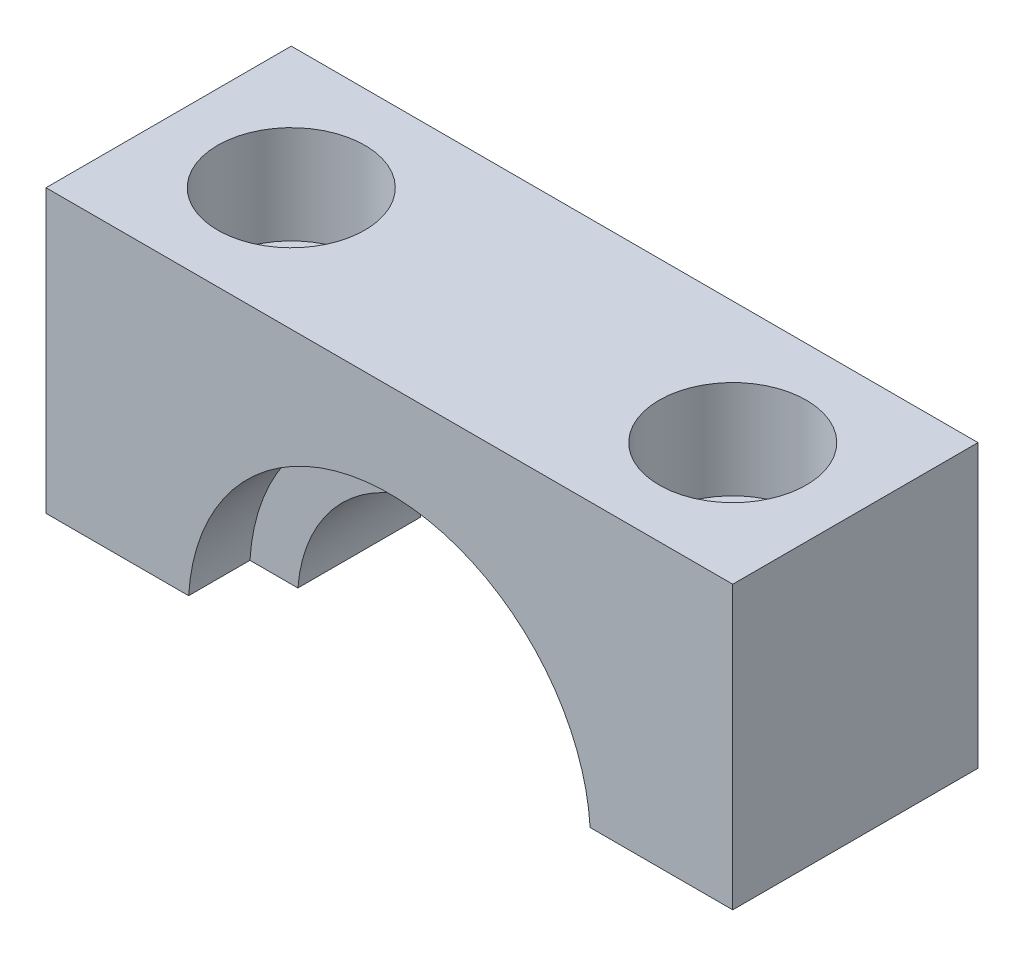
from build123d import *

# Parameters (mm, degrees)
RESSALTO_EXTRUS_O1_DEPTH = 2.5
RESSALTO_EXTRUS_O2_DEPTH = 5
ESBO_O2_R                = 1.65
CORTE_EXTRUS_O1_DEPTH    = 15
ESBO_O4_R                = 3
CORTE_EXTRUS_O2_DEPTH    = 4


with BuildPart() as part:
    # Esboço1 → Ressalto-extrusão1 (new body, symmetric)
    with BuildSketch(Plane.XY):
        with BuildLine():
            Line((-6.229967897, 0.5), (-14, 0.5))
            Line((-14, 0.5), (-14, 12))
            Line((-14, 12), (14, 12))
            Line((14, 12), (14, 0.5))
            Line((14, 0.5), (6.229967897, 0.5))
            ThreePointArc((6.229967897, 0.5), (0, 6.25), (-6.229967897, 0.5))
        make_face()
    extrude(amount=RESSALTO_EXTRUS_O1_DEPTH, both=True)

    # Esboço3 → Ressalto-extrusão2 (add, symmetric)
    with BuildSketch(Plane.XY):
        with BuildLine():
            Line((-14, 12), (-14, 0.5))
            Line((-14, 0.5), (-8.184741902, 0.5))
            ThreePointArc((-8.184741902, 0.5), (0, 8.2), (8.184741902, 0.5))
            Line((8.184741902, 0.5), (14, 0.5))
            Line((14, 0.5), (14, 12))
            Line((14, 12), (-14, 12))
        make_face()
    extrude(amount=RESSALTO_EXTRUS_O2_DEPTH, both=True)

    # Esboço2 → Corte-extrusão1 (cut)
    with BuildSketch(Plane.XZ.offset(-0.5)):
        with Locations((-9, 0)):
            Circle(ESBO_O2_R)
        with Locations((9, 0)):
            Circle(ESBO_O2_R)
    extrude(amount=-CORTE_EXTRUS_O1_DEPTH, mode=Mode.SUBTRACT)

    # Esboço4 → Corte-extrusão2 (cut)
    with BuildSketch(Plane(origin=(0, 12, 0), x_dir=(1, 0, 0), z_dir=(0, 1, 0))):
        with Locations((-9, 0)):
            Circle(ESBO_O4_R)
        with Locations((9, 0)):
            Circle(ESBO_O4_R)
    extrude(amount=-CORTE_EXTRUS_O2_DEPTH, mode=Mode.SUBTRACT)


solid = part.part
